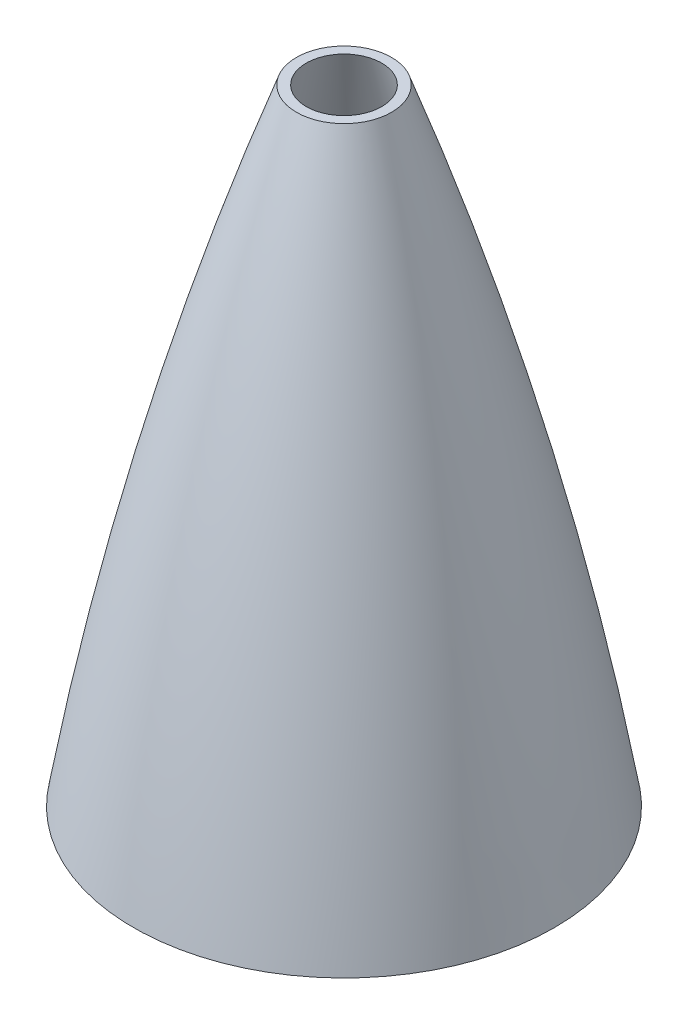
from build123d import *

# Parameters (mm, degrees)
SKETCH7_R           = 317.5
CUT_EXTRUDE2_DEPTH  = 88.9
SKETCH8_R           = 73.025
SKETCH8_R_2         = 69.85
BOSS_EXTRUDE1_DEPTH = 76.2
SKETCH9_R           = 87.299275162
CUT_EXTRUDE3_DEPTH  = 177.8


with BuildPart() as part:
    # Sketch2 → Revolve1 (revolve)
    with BuildSketch(Plane.XY):
        with BuildLine():
            Line((-76.2, 0), (-69.85, 0))
            ThreePointArc((-69.85, 0), (-46.178344337, 164.977710697), (0, 325.12))
            Line((0, 325.12), (0, 330.2))
            ThreePointArc((0, 330.2), (-50.970594074, 168.070137094), (-76.2, 0))
        make_face()
    revolve(axis=Axis((0, 330.2, 0), (0, -1, 0)))

    # Sketch7 → Cut-Extrude2 (cut)
    with BuildSketch(Plane(origin=(0, 381, 0), x_dir=(1, 0, 0), z_dir=(0, 1, 0))):
        Circle(SKETCH7_R)
    extrude(amount=-CUT_EXTRUDE2_DEPTH, mode=Mode.SUBTRACT)

    # Sketch8 → Boss-Extrude1 (add)
    with BuildSketch(Plane.XZ):
        Circle(SKETCH8_R)
        Circle(SKETCH8_R_2, mode=Mode.SUBTRACT)
    extrude(amount=BOSS_EXTRUDE1_DEPTH)

    # Sketch9 → Cut-Extrude3 (cut)
    with BuildSketch(Plane.XZ.offset(76.2)):
        Circle(SKETCH9_R)
    extrude(amount=-CUT_EXTRUDE3_DEPTH, mode=Mode.SUBTRACT)


solid = part.part
